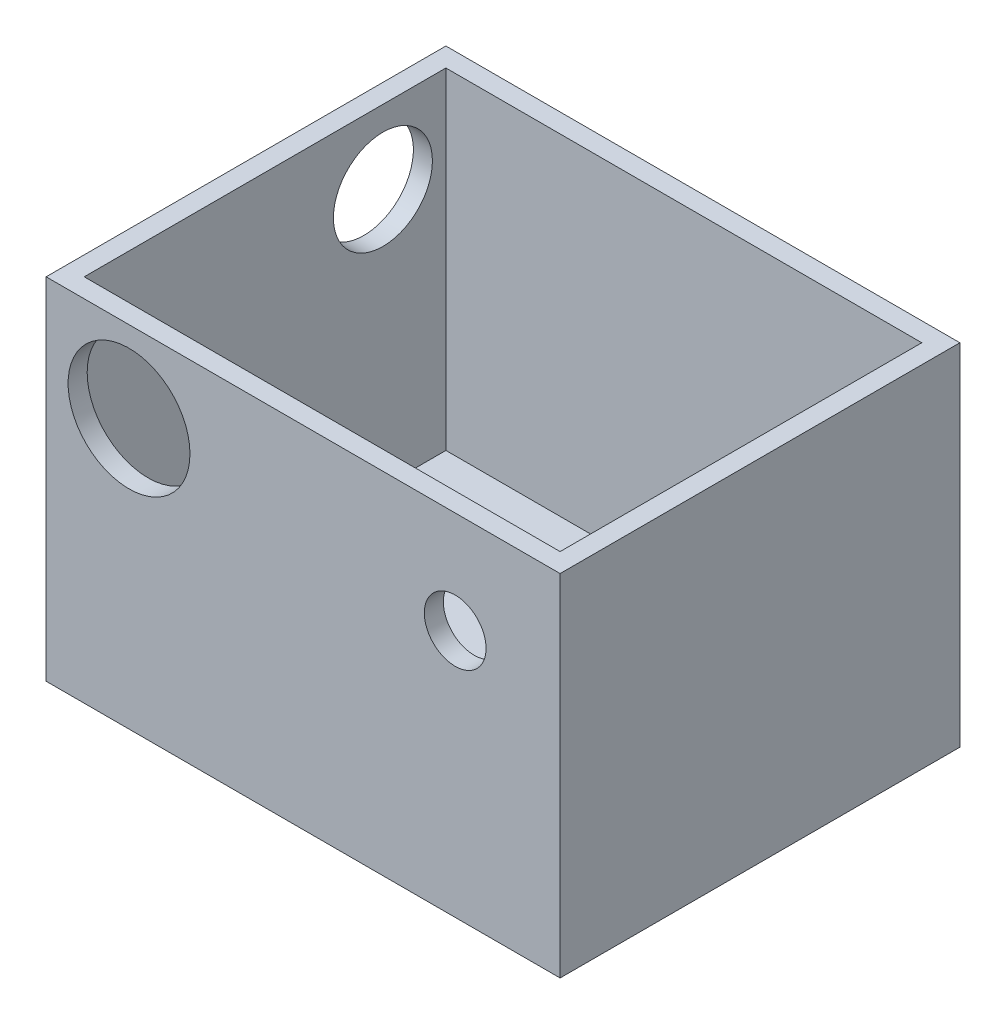
from build123d import *

# Parameters (mm, degrees)
SKETCH1_W           = 85.725
SKETCH1_H           = 66.675
BOSS_EXTRUDE2_DEPTH = 58.42
SHELL1_T            = -3.175
HOLE1_REACH         = 100.466
HOLE1_BORE_R        = 10.16
HOLE2_D             = 16.51
HOLE2_DEPTH         = 3.175
HOLE3_D             = 10.3
HOLE3_DEPTH         = 3.175


with BuildPart() as part:
    # Sketch1 → Boss-Extrude2 (new body)
    with BuildSketch(Plane(origin=(0, 0, 0), x_dir=(1, 0, 0), z_dir=(0, 1, 0))):
        Rectangle(SKETCH1_W, SKETCH1_H)
    extrude(amount=BOSS_EXTRUDE2_DEPTH)

    # Shell1
    shell1_openings = [part.faces().sort_by_distance(p)[0] for p in [
        (0, 58.42, 0),
    ]]
    offset(amount=SHELL1_T, openings=shell1_openings, kind=Kind.INTERSECTION)

    # Hole1 bore → Hole1 (cut, up to next)
    with BuildSketch(Plane.XY.offset(33.3375), mode=Mode.PRIVATE) as hole1_sk1:
        with Locations((-29.033498957, 44.858810897)):
            Circle(HOLE1_BORE_R)
    hole1_tool1 = extrude(hole1_sk1.sketch, amount=-HOLE1_REACH, mode=Mode.PRIVATE) & part.part
    add(hole1_tool1.solids().sort_by_distance((-29.033499, 44.858811, 33.3375))[0], mode=Mode.SUBTRACT)

    # Hole2
    with Locations(Plane.ZY.offset(42.8625)):
        with Locations((-19.658206751, 46.146926064)):
            Hole(HOLE2_D / 2, depth=HOLE2_DEPTH)

    # Hole3
    with Locations(Plane.XY.offset(33.3375)):
        with Locations((25.3625, 41.42)):
            Hole(HOLE3_D / 2, depth=HOLE3_DEPTH)


solid = part.part
